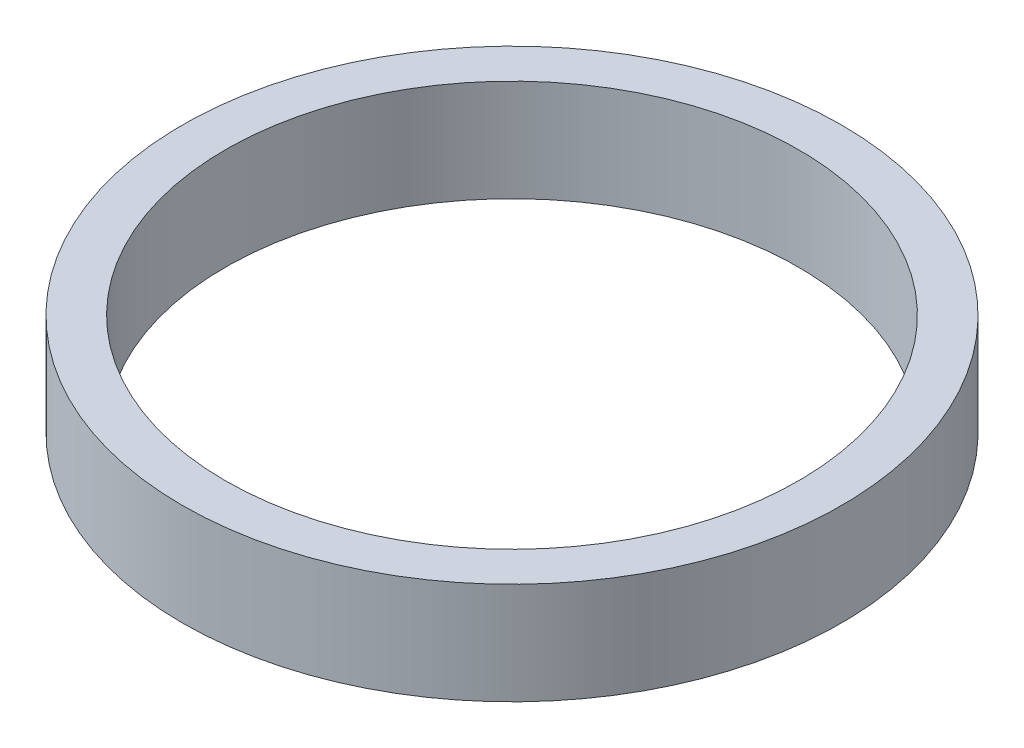
from build123d import *

# Parameters (mm, degrees)
SKETCH1_R           = 61.5
SKETCH1_R_2         = 53.5
BOSS_EXTRUDE1_DEPTH = 19


with BuildPart() as part:
    # Sketch1 → Boss-Extrude1 (new body)
    with BuildSketch(Plane(origin=(0, 0, 0), x_dir=(1, 0, 0), z_dir=(0, 1, 0))):
        Circle(SKETCH1_R)
        Circle(SKETCH1_R_2, mode=Mode.SUBTRACT)
    extrude(amount=BOSS_EXTRUDE1_DEPTH)


solid = part.part
